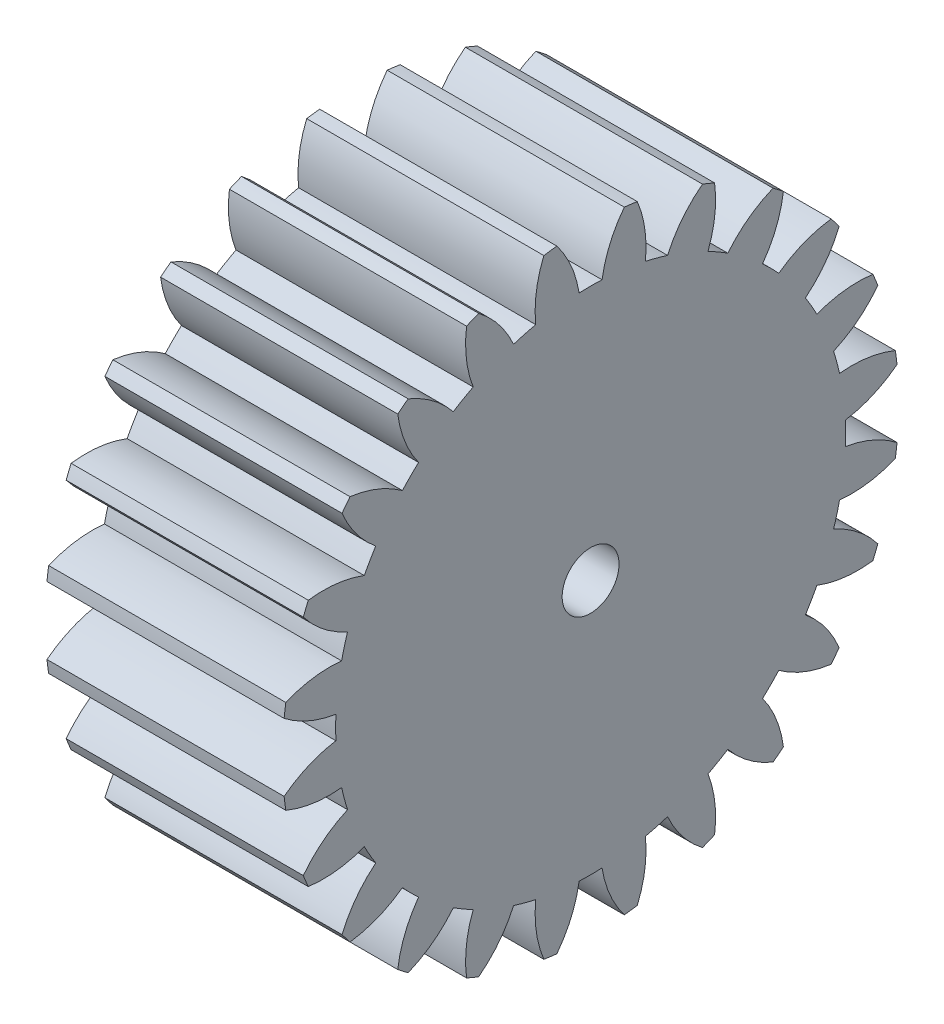
from build123d import *

# Parameters (mm, degrees)
BASPROSKE_W     = 10
BASPROSKE_H     = 13
TOOTHCUT_DEPTH  = 21.928449536
TEETHCUTS_COUNT = 24
TEETHCUTS_ANGLE = 345
BORSKE_R        = 1.2
BORE_DEPTH      = 50.0000508


with BuildPart() as part:
    # BasProSke → Base-Revolve (revolve)
    with BuildSketch(Plane(origin=(0, 0, 0), x_dir=(1, 0, 0), z_dir=(0, 1, 0)), mode=Mode.PRIVATE) as base_revolve_sk:
        with Locations((5, 6.5)):
            Rectangle(BASPROSKE_W, BASPROSKE_H)
    revolve(base_revolve_sk.sketch.rotate(Axis((-10, 0, 0), (1, 0, 0)), 180), axis=Axis((-10, 0, 0), (1, 0, 0)))

    # TooCutSke → ToothCut (cut, through all)
    with BuildSketch(Plane(origin=(0, 0, 0), x_dir=(0, 0, -1), z_dir=(1, 0, 0))):
        with BuildLine():
            ThreePointArc((0.483448384, 10.738122679), (0, 10.749), (-0.483448384, 10.738122679))
            ThreePointArc((-0.483448384, 10.738122679), (-0.821636462, 11.902754369), (-1.44092227, 12.945454344))
            ThreePointArc((-1.44092227, 12.945454344), (0, 13.0254), (1.44092227, 12.945454344))
            ThreePointArc((1.44092227, 12.945454344), (0.821636462, 11.902754369), (0.483448384, 10.738122679))
        make_face()
    toothcut = extrude(amount=TOOTHCUT_DEPTH, mode=Mode.SUBTRACT)

    # TeethCuts: ToothCut ×24 about axis
    teethcuts_axis = Axis((-10, 0, 0), (1, 0, 0))
    for i in range(1, TEETHCUTS_COUNT):
        add(toothcut.rotate(teethcuts_axis, i * TEETHCUTS_ANGLE / (TEETHCUTS_COUNT - 1)), mode=Mode.SUBTRACT)

    # BorSke → Bore (cut, symmetric)
    with BuildSketch(Plane(origin=(0, 0, 0), x_dir=(0, 0, -1), z_dir=(1, 0, 0))):
        with Locations(Location((0, 0, 0), (0, 0, 180))):
            Circle(BORSKE_R)
    extrude(amount=BORE_DEPTH, both=True, mode=Mode.SUBTRACT)


solid = part.part
